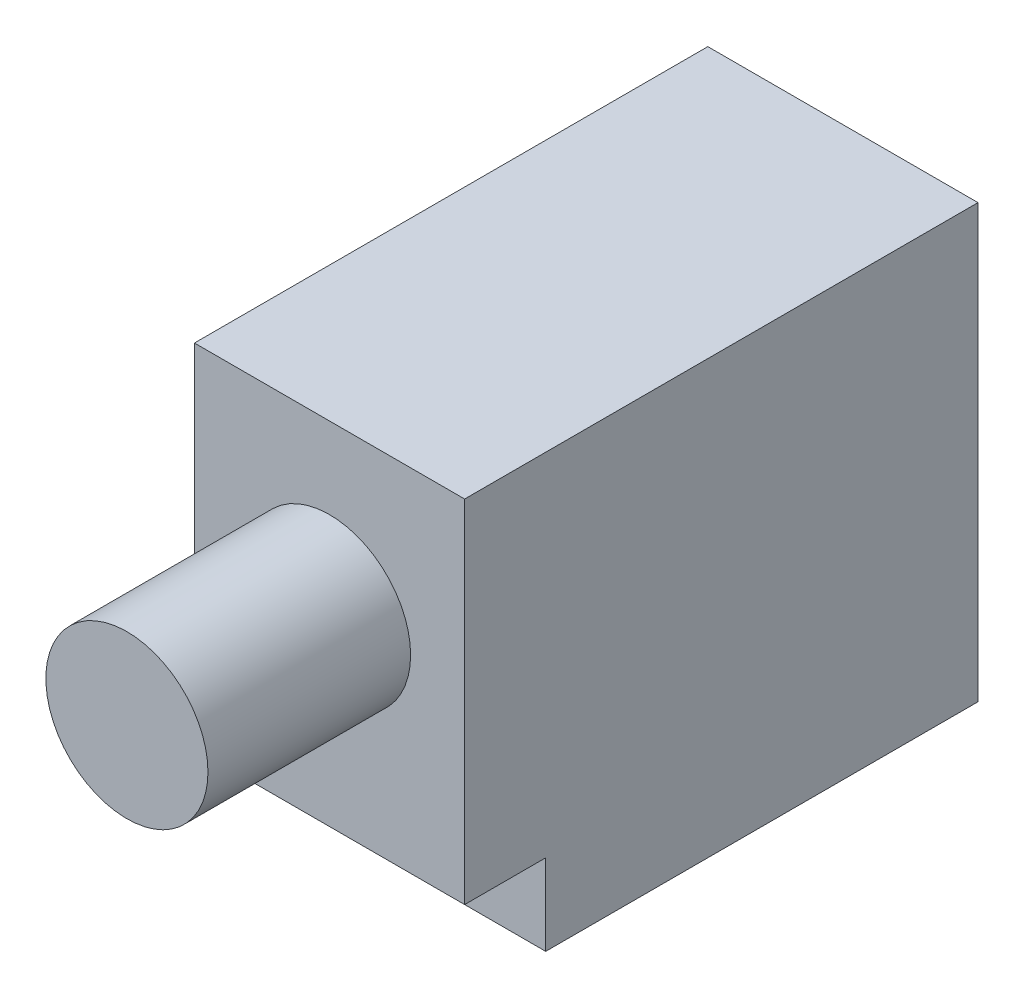
from build123d import *

# Parameters (mm, degrees)
SKETCH1_W           = 30.1625
SKETCH1_H           = 25.4
BOSS_EXTRUDE1_DEPTH = 15.875
SKETCH2_R           = 4.7625
BOSS_EXTRUDE2_DEPTH = 11.90625
SKETCH3_W           = 4.7625
SKETCH3_H           = 4.7625
CUT_EXTRUDE1_DEPTH  = 16.875


with BuildPart() as part:
    # Sketch1 → Boss-Extrude1 (new body)
    with BuildSketch(Plane(origin=(0, 0, 0), x_dir=(0, 0, -1), z_dir=(1, 0, 0))):
        Rectangle(SKETCH1_W, SKETCH1_H)
    extrude(amount=BOSS_EXTRUDE1_DEPTH)

    # Sketch2 → Boss-Extrude2 (add)
    with BuildSketch(Plane.XY.offset(15.08125)):
        with Locations((7.9375, 3.175)):
            Circle(SKETCH2_R)
    extrude(amount=BOSS_EXTRUDE2_DEPTH)

    # Sketch3 → Cut-Extrude1 (cut, through all)
    with BuildSketch(Plane(origin=(15.875, 0, 0), x_dir=(0, 0, -1), z_dir=(1, 0, 0))):
        with Locations((-12.7, -10.31875)):
            Rectangle(SKETCH3_W, SKETCH3_H)
    extrude(amount=-CUT_EXTRUDE1_DEPTH, mode=Mode.SUBTRACT)


solid = part.part
